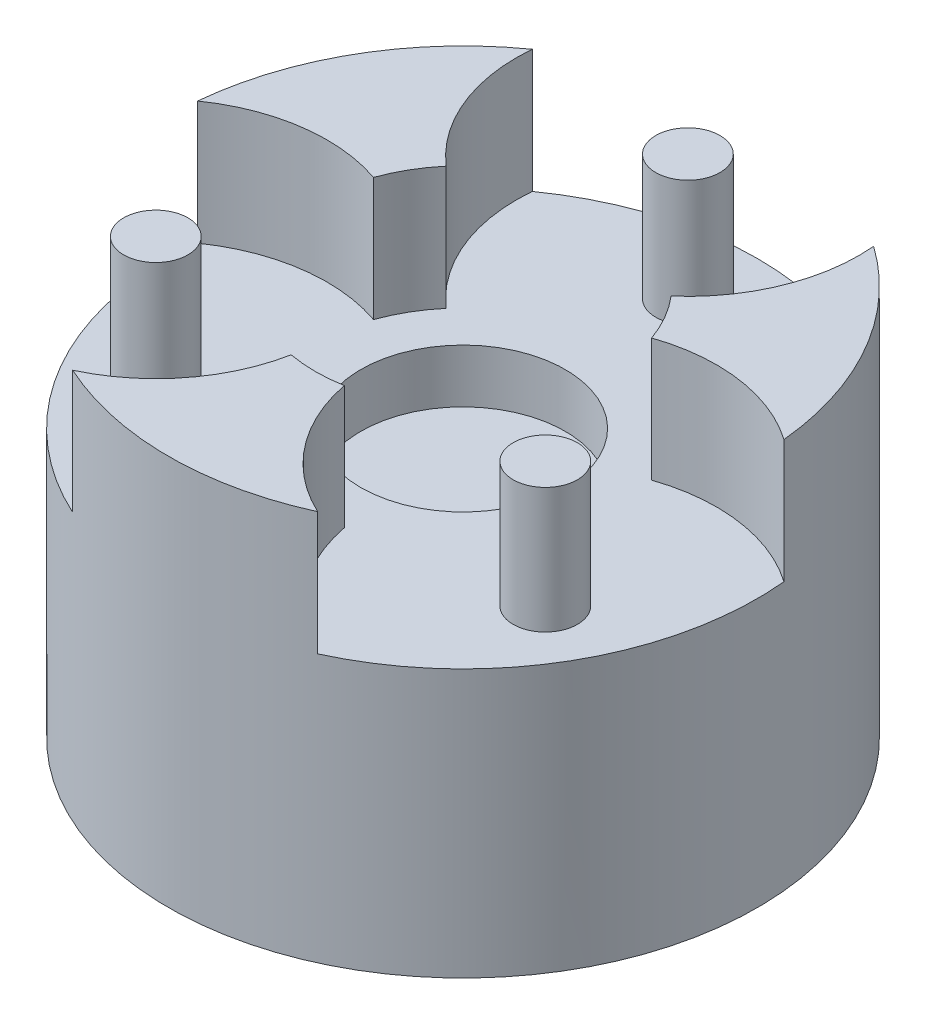
from build123d import *

# Parameters (mm, degrees)
SKETCH1_R           = 27.5
SKETCH1_R_2         = 9.55
BOSS_EXTRUDE1_DEPTH = 5
SKETCH2_R           = 3
BOSS_EXTRUDE2_DEPTH = 11.7
BOSS_EXTRUDE3_DEPTH = 11.5
SKETCH6_R           = 27.5
BOSS_EXTRUDE4_DEPTH = 20


with BuildPart() as part:
    # Sketch1 → Boss-Extrude1 (new body)
    with BuildSketch(Plane(origin=(0, 0, 0), x_dir=(1, 0, 0), z_dir=(0, 1, 0))):
        Circle(SKETCH1_R)
        Circle(SKETCH1_R_2, mode=Mode.SUBTRACT)
    extrude(amount=BOSS_EXTRUDE1_DEPTH)

    # Sketch2 → Boss-Extrude2 (add)
    with BuildSketch(Plane(origin=(0, 5, 0), x_dir=(1, 0, 0), z_dir=(0, 1, 0))):
        with Locations((0, 21)):
            Circle(SKETCH2_R)
        with Locations((18.186533479, -10.5)):
            Circle(SKETCH2_R)
        with Locations((-18.186533479, -10.5)):
            Circle(SKETCH2_R)
    extrude(amount=BOSS_EXTRUDE2_DEPTH)

    # Sketch3 → Boss-Extrude3 (add)
    with BuildSketch(Plane(origin=(0, 5, 0), x_dir=(1, 0, 0), z_dir=(0, 1, 0))):
        with BuildLine():
            ThreePointArc((-15.937687574, 22.410714286), (-14.839908311, 15.01860206), (-10.504684652, 8.931379517))
            ThreePointArc((-10.504684652, 8.931379517), (-11.941040775, 6.894163106), (-12.987143879, 4.631634009))
            ThreePointArc((-12.987143879, 4.631634009), (-20.426445069, 5.342436557), (-27.377091675, 2.597085174))
            ThreePointArc((-27.377091675, 2.597085174), (-23.815698604, 13.75), (-15.937687574, 22.410714286))
        make_face()
        with BuildLine():
            ThreePointArc((2.482459227, -13.563013526), (5.586536758, -20.361038617), (11.439404101, -25.007799459))
            ThreePointArc((11.439404101, -25.007799459), (0, -27.5), (-11.439404101, -25.007799459))
            ThreePointArc((-11.439404101, -25.007799459), (-5.586536758, -20.361038617), (-2.482459227, -13.563013526))
            ThreePointArc((-2.482459227, -13.563013526), (0, -13.788326212), (2.482459227, -13.563013526))
        make_face()
        with BuildLine():
            ThreePointArc((10.504684652, 8.931379517), (14.839908311, 15.01860206), (15.937687574, 22.410714286))
            ThreePointArc((15.937687574, 22.410714286), (23.815698604, 13.75), (27.377091675, 2.597085174))
            ThreePointArc((27.377091675, 2.597085174), (20.426445069, 5.342436557), (12.987143879, 4.631634009))
            ThreePointArc((12.987143879, 4.631634009), (11.941040775, 6.894163106), (10.504684652, 8.931379517))
        make_face()
    extrude(amount=BOSS_EXTRUDE3_DEPTH)

    # Sketch6 → Boss-Extrude4 (add)
    with BuildSketch(Plane.XZ):
        Circle(SKETCH6_R)
    extrude(amount=BOSS_EXTRUDE4_DEPTH)


solid = part.part
